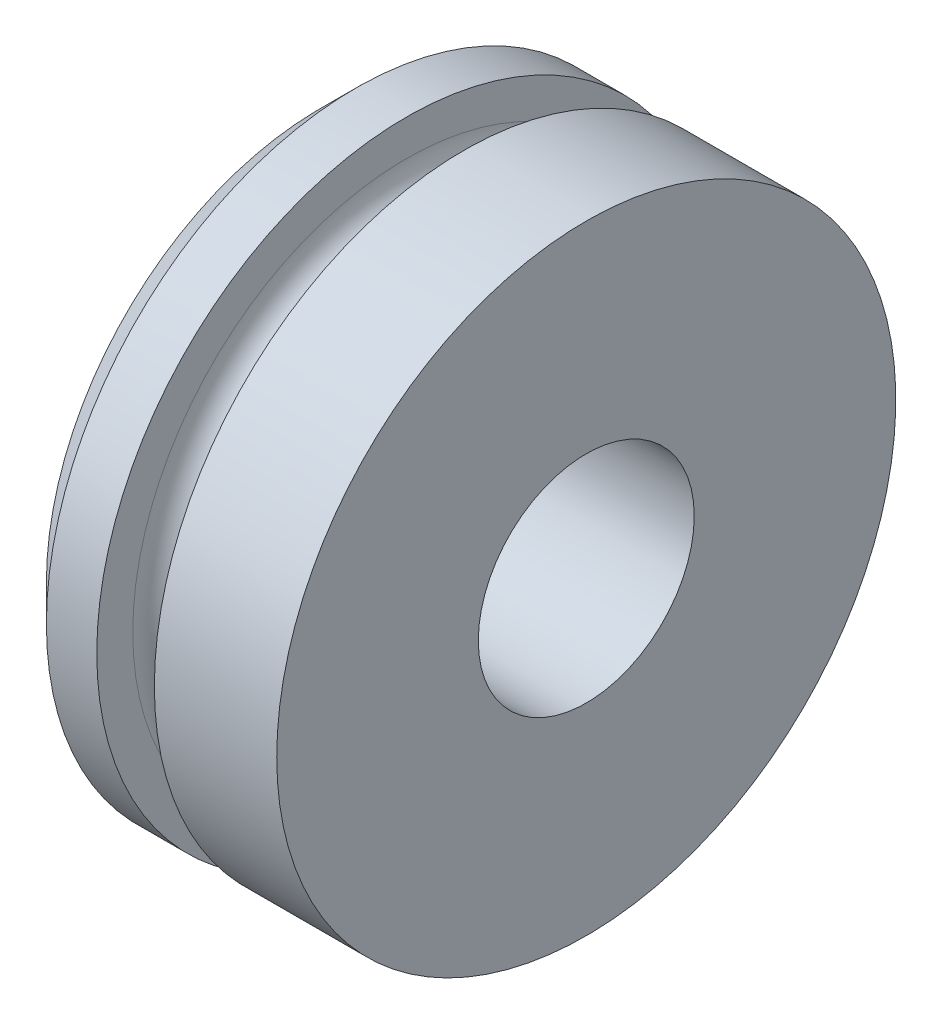
from build123d import *

# Parameters (mm, degrees)
CHAMFER1_SIZE = 3.175


with BuildPart() as part:
    # Sketch1 → Revolve1 (revolve)
    with BuildSketch(Plane.XY):
        with BuildLine():
            Line((0, 27.305), (0, 9.525))
            Line((0, 9.525), (23.495, 9.525))
            Line((23.495, 9.525), (23.495, 27.305))
            Line((23.495, 27.305), (12.7, 27.305))
            Line((12.7, 27.305), (12.7, 24.13))
            ThreePointArc((12.7, 24.13), (10.16, 21.59), (7.62, 24.13))
            Line((7.62, 24.13), (7.62, 27.305))
            Line((7.62, 27.305), (0, 27.305))
        make_face()
    revolve(axis=Axis((0, 0, 0), (1, 0, 0)))

    # Chamfer1
    chamfer1_edges = [part.edges().sort_by_distance(p)[0] for p in [
        (0, -27.305, 0),
    ]]
    chamfer(chamfer1_edges, length=CHAMFER1_SIZE)


solid = part.part
